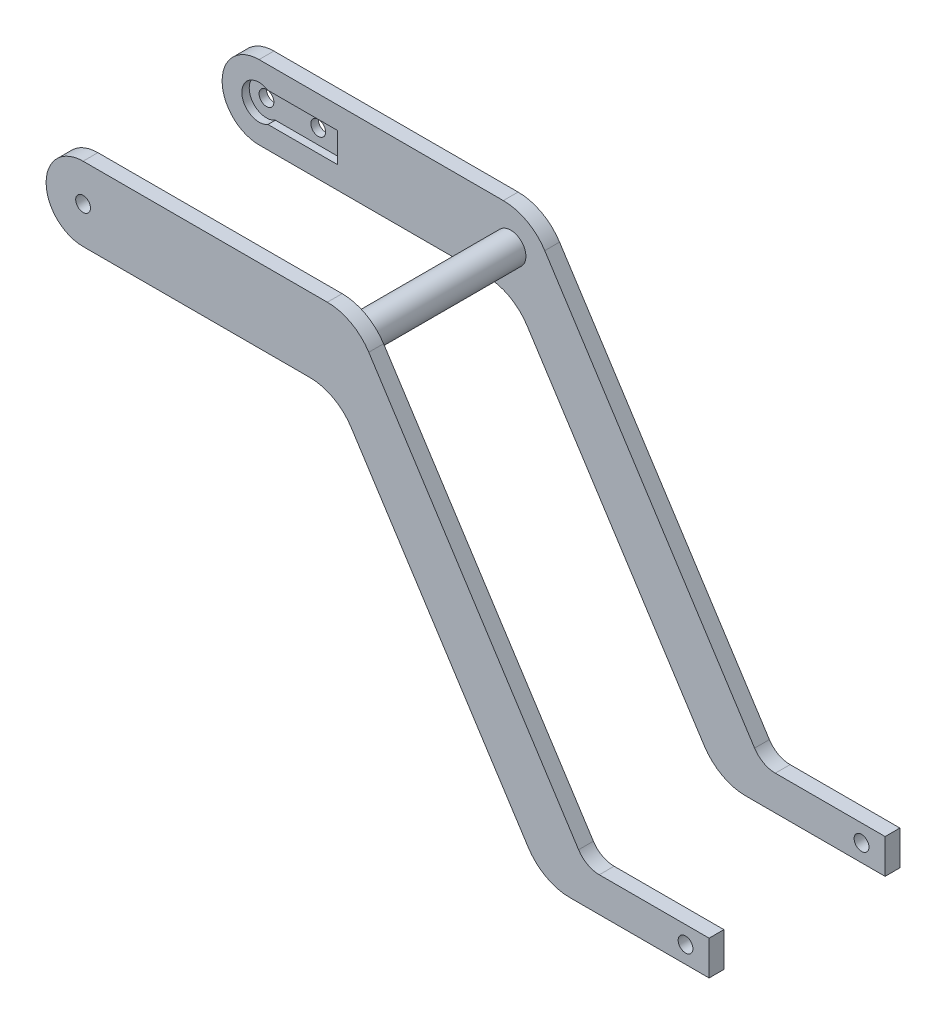
from build123d import *

# Parameters (mm, degrees)
SKETCH_324_R             = 1.5
EXTRUDE_1_DEPTH          = 3
SKETCH_2_R               = 1.5
CUT_EXTRUDE_1_DEPTH      = 111.5
CUT_EXTRUDE_1_DEPTH_BACK = 41.5
CUT_EXTRUDE_2_DEPTH      = 1.5
SKETCH_6_R               = 1.5
CUT_EXTRUDE_3_DEPTH      = 2.5
SKETCH_8_R               = 3.075
EXTRUDE_3_DEPTH          = 16.35
MIRROR_8_COPY_1_SKETCH_R = 3.075
MIRROR_8_COPY_1_DEPTH    = 16.35
MIRROR_8_COPY_2_SKETCH_R = 3.075
MIRROR_8_COPY_2_DEPTH    = 16.35
SKETCH_11_R              = 1.5
CUT_EXTRUDE_4_DEPTH      = 41.5


with BuildPart() as part:
    # Sketch 324 → 填料-伸長1 (new body)
    with BuildSketch(Plane.XY):
        with BuildLine():
            ThreePointArc((100.510480498, -70.70616545), (102.320143894, -72.389238388), (104.714843536, -73))
            Line((104.714843536, -73), (126.986921935, -73))
            Line((126.986921935, -73), (126.986921935, -80))
            Line((126.986921935, -80), (98.725740556, -80))
            ThreePointArc((98.725740556, -80), (93.936341272, -78.778476776), (90.317014479, -75.4123309))
            Line((90.317014479, -75.4123309), (54.385110012, -19.5876691))
            ThreePointArc((54.385110012, -19.5876691), (50.76578322, -16.221523224), (45.976383936, -15))
            Line((45.976383936, -15), (2.168890098, -15))
            Line((2.168890098, -15), (0, -15))
            ThreePointArc((0, -15), (-7.5, -7.5), (0, 0))
            Line((0, 0), (49.544156798, 0))
            ThreePointArc((49.544156798, 0), (54.333556082, -1.221523224), (57.952882875, -4.5876691))
            Line((57.952882875, -4.5876691), (100.510480498, -70.70616545))
        make_face()
        with Locations((0, -7.5)):
            Circle(SKETCH_324_R, mode=Mode.SUBTRACT)
    extrude_1 = extrude(amount=EXTRUDE_1_DEPTH)

    # 草圖2 → 除料-伸長1 (cut, two sides)
    with BuildSketch(Plane.XY.offset(3)) as cut_extrude_1_sk:
        with Locations((122.206921935, -76.5)):
            Circle(SKETCH_2_R)
    extrude(amount=CUT_EXTRUDE_1_DEPTH, mode=Mode.SUBTRACT)
    extrude(cut_extrude_1_sk.sketch, amount=-CUT_EXTRUDE_1_DEPTH_BACK, mode=Mode.SUBTRACT)

    # 草圖5 → 除料-伸長2 (cut)
    with BuildSketch(Plane.XY.offset(3)):
        with BuildLine():
            Line((1.802775638, -4.5), (15.929780582, -4.5))
            Line((15.929780582, -4.5), (15.929780582, -10.5))
            Line((15.929780582, -10.5), (1.802775638, -10.5))
            ThreePointArc((1.802775638, -10.5), (-3.5, -7.5), (1.802775638, -4.5))
        make_face()
    extrude(amount=-CUT_EXTRUDE_2_DEPTH, mode=Mode.SUBTRACT)

    # 草圖6 → 除料-伸長3 (cut, through all)
    with BuildSketch(Plane.XY.offset(1.5)):
        with Locations((10.5, -7.5)):
            Circle(SKETCH_6_R)
    extrude(amount=-CUT_EXTRUDE_3_DEPTH, mode=Mode.SUBTRACT)

    # 草圖8 → 填料-伸長3 (add)
    with BuildSketch(Plane.XY.offset(3)):
        with Locations((51.04897254, -7.515441374)):
            Circle(SKETCH_8_R)
    extrude_3 = extrude(amount=EXTRUDE_3_DEPTH)

    # 鏡射7: 填料-伸長3 across plane
    add(extrude_3.mirror(Plane.XY.offset(19.35)))

    # 鏡射8: 填料-伸長1 across plane
    add(extrude_1.mirror(Plane.XY.offset(19.35)))

    # 鏡射8 copy 1 sketch → 鏡射8 copy 1 (add)
    with BuildSketch(Plane.XY.offset(3)):
        with Locations((51.04897254, -7.515441374)):
            Circle(MIRROR_8_COPY_1_SKETCH_R)
    extrude(amount=MIRROR_8_COPY_1_DEPTH)

    # 鏡射8 copy 2 sketch → 鏡射8 copy 2 (add)
    with BuildSketch(Plane(origin=(0, 0, 35.7), x_dir=(1, 0, 0), z_dir=(0, 0, -1))):
        with Locations((51.04897254, 7.515441374)):
            Circle(MIRROR_8_COPY_2_SKETCH_R)
    extrude(amount=MIRROR_8_COPY_2_DEPTH)

    # 草圖11 → 除料-伸長4 (cut)
    with BuildSketch(Plane(origin=(0, 0, 35.7), x_dir=(-1, 0, 0), z_dir=(0, 0, -1))):
        with Locations((-122.206921935, -76.5)):
            Circle(SKETCH_11_R)
    extrude(amount=-CUT_EXTRUDE_4_DEPTH, mode=Mode.SUBTRACT)


solid = part.part
